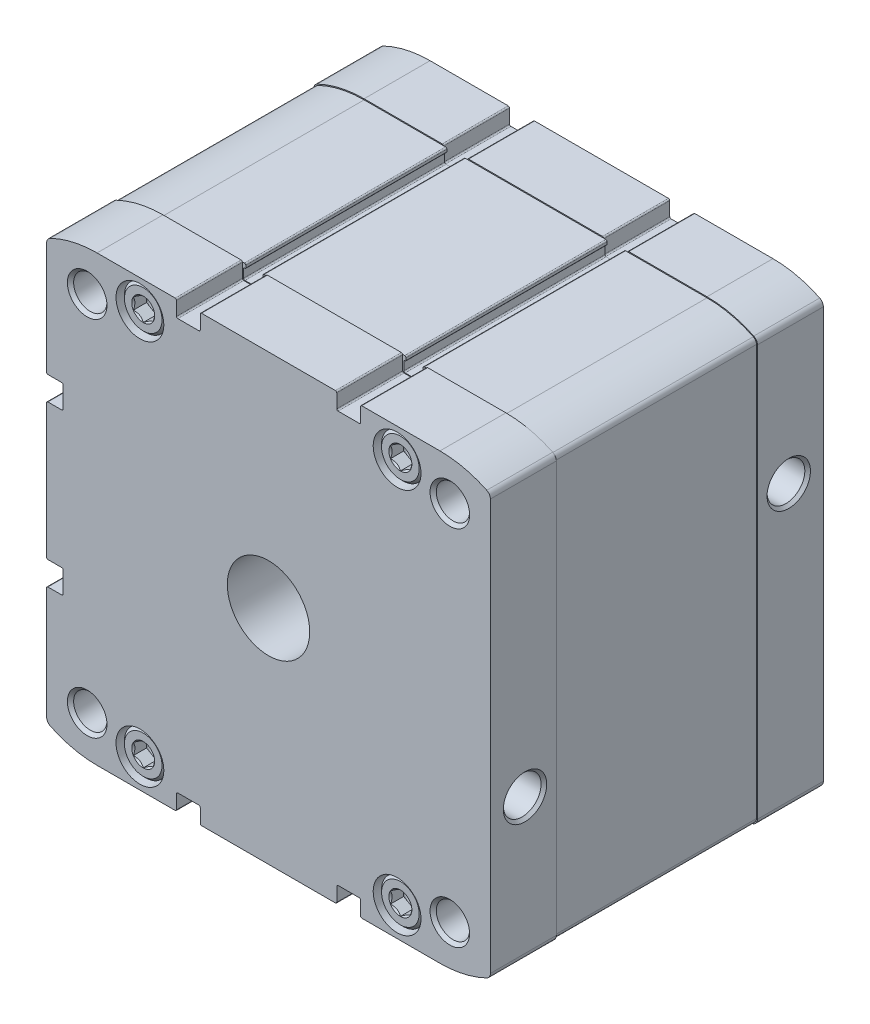
from build123d import *

# Parameters (mm, degrees)
BOSS_EXTRUDE1_DEPTH = 101
SKETCH2_W           = 134
SKETCH2_H           = 134
BOSS_EXTRUDE2_DEPTH = 61
SKETCH3_W           = 200
SKETCH3_H           = 200
CUT_EXTRUDE1_DEPTH  = 61
SKETCH7_W           = 2.6
SKETCH7_H           = 6
CUT_EXTRUDE2_DEPTH  = 4
CUT_EXTRUDE3_DEPTH  = 4
CUT_EXTRUDE4_DEPTH  = 4
CUT_EXTRUDE5_DEPTH  = 4
CUT_EXTRUDE6_DEPTH  = 4
CUT_EXTRUDE7_DEPTH  = 4
CUT_EXTRUDE8_DEPTH  = 4
CUT_EXTRUDE9_DEPTH  = 4
SKETCH29_W          = 61
SKETCH29_H          = 5.5
SKETCH31_W          = 61
SKETCH31_H          = 5.5
SKETCH33_W          = 61
SKETCH33_H          = 5.5
SKETCH35_W          = 61
SKETCH35_H          = 5.5


with BuildPart() as part:
    # Sketch1 → Boss-Extrude1 (new body)
    with BuildSketch(Plane.XY):
        with BuildLine():
            Line((-66.9, 27.9), (-62.7, 27.9))
            ThreePointArc((-62.7, 27.9), (-62.417157288, 27.782842712), (-62.3, 27.5))
            Line((-62.3, 27.5), (-62.3, 21.1))
            ThreePointArc((-62.3, 21.1), (-62.417157288, 20.817157288), (-62.7, 20.7))
            Line((-62.7, 20.7), (-66.9, 20.7))
            ThreePointArc((-66.9, 20.7), (-67.182842712, 20.582842712), (-67.3, 20.3))
            Line((-67.3, 20.3), (-67.3, -20.3))
            ThreePointArc((-67.3, -20.3), (-67.182842712, -20.582842712), (-66.9, -20.7))
            Line((-66.9, -20.7), (-62.7, -20.7))
            ThreePointArc((-62.7, -20.7), (-62.417157288, -20.817157288), (-62.3, -21.1))
            Line((-62.3, -21.1), (-62.3, -27.5))
            ThreePointArc((-62.3, -27.5), (-62.417157288, -27.782842712), (-62.7, -27.9))
            Line((-62.7, -27.9), (-66.9, -27.9))
            ThreePointArc((-66.9, -27.9), (-67.182842712, -28.017157288), (-67.3, -28.3))
            Line((-67.3, -28.3), (-67.3, -62.300902512))
            ThreePointArc((-67.3, -62.300902512), (-67.001263477, -63.338124248), (-66.196585713, -64.057544943))
            ThreePointArc((-66.196585713, -64.057544943), (-59.281080976, -66.479081854), (-52, -67.3))
            Line((-52, -67.3), (-28.3, -67.3))
            ThreePointArc((-28.3, -67.3), (-28.017157288, -67.182842712), (-27.9, -66.9))
            Line((-27.9, -66.9), (-27.9, -62.7))
            ThreePointArc((-27.9, -62.7), (-27.782842712, -62.417157288), (-27.5, -62.3))
            Line((-27.5, -62.3), (-21.1, -62.3))
            ThreePointArc((-21.1, -62.3), (-20.817157288, -62.417157288), (-20.7, -62.7))
            Line((-20.7, -62.7), (-20.7, -66.9))
            ThreePointArc((-20.7, -66.9), (-20.582842712, -67.182842712), (-20.3, -67.3))
            Line((-20.3, -67.3), (20.3, -67.3))
            ThreePointArc((20.3, -67.3), (20.582842712, -67.182842712), (20.7, -66.9))
            Line((20.7, -66.9), (20.7, -62.7))
            ThreePointArc((20.7, -62.7), (20.817157288, -62.417157288), (21.1, -62.3))
            Line((21.1, -62.3), (27.5, -62.3))
            ThreePointArc((27.5, -62.3), (27.782842712, -62.417157288), (27.9, -62.7))
            Line((27.9, -62.7), (27.9, -66.9))
            ThreePointArc((27.9, -66.9), (28.017157288, -67.182842712), (28.3, -67.3))
            Line((28.3, -67.3), (52, -67.3))
            ThreePointArc((52, -67.3), (59.281080788, -66.479081896), (66.196585366, -64.057545111))
            ThreePointArc((66.196585366, -64.057545111), (67.001263374, -63.338124412), (67.3, -62.300902512))
            Line((67.3, -62.300902512), (67.3, 62.300902512))
            ThreePointArc((67.3, 62.300902512), (67.001263433, 63.338124318), (66.196585566, 64.057545014))
            ThreePointArc((66.196585566, 64.057545014), (59.281080896, 66.479081872), (52, 67.3))
            Line((52, 67.3), (28.3, 67.3))
            ThreePointArc((28.3, 67.3), (28.017157288, 67.182842712), (27.9, 66.9))
            Line((27.9, 66.9), (27.9, 62.7))
            ThreePointArc((27.9, 62.7), (27.782842712, 62.417157288), (27.5, 62.3))
            Line((27.5, 62.3), (21.1, 62.3))
            ThreePointArc((21.1, 62.3), (20.817157288, 62.417157288), (20.7, 62.7))
            Line((20.7, 62.7), (20.7, 66.9))
            ThreePointArc((20.7, 66.9), (20.582842712, 67.182842712), (20.3, 67.3))
            Line((20.3, 67.3), (-20.3, 67.3))
            ThreePointArc((-20.3, 67.3), (-20.582842712, 67.182842712), (-20.7, 66.9))
            Line((-20.7, 66.9), (-20.7, 62.7))
            ThreePointArc((-20.7, 62.7), (-20.817157288, 62.417157288), (-21.1, 62.3))
            Line((-21.1, 62.3), (-27.5, 62.3))
            ThreePointArc((-27.5, 62.3), (-27.782842712, 62.417157288), (-27.9, 62.7))
            Line((-27.9, 62.7), (-27.9, 66.9))
            ThreePointArc((-27.9, 66.9), (-28.017157288, 67.182842712), (-28.3, 67.3))
            Line((-28.3, 67.3), (-52, 67.3))
            ThreePointArc((-52, 67.3), (-59.281080788, 66.479081896), (-66.196585366, 64.057545111))
            ThreePointArc((-66.196585366, 64.057545111), (-67.001263374, 63.338124412), (-67.3, 62.300902512))
            Line((-67.3, 62.300902512), (-67.3, 28.3))
            ThreePointArc((-67.3, 28.3), (-67.182842712, 28.017157288), (-66.9, 27.9))
        make_face()
    extrude(amount=-BOSS_EXTRUDE1_DEPTH)

    # Sketch2 → Boss-Extrude2 (add)
    with BuildSketch(Plane.XY.offset(-20)):
        Rectangle(SKETCH2_W, SKETCH2_H)
    extrude(amount=-BOSS_EXTRUDE2_DEPTH)

    # Sketch3 → Cut-Extrude1 (cut)
    with BuildSketch(Plane.XY.offset(-20)):
        Rectangle(SKETCH3_W, SKETCH3_H)
        with BuildLine():
            Line((-66.6, 26.9), (-65.9, 26.9))
            ThreePointArc((-65.9, 26.9), (-65.758578644, 26.958578644), (-65.7, 27.1))
            Line((-65.7, 27.1), (-65.7, 27.35))
            ThreePointArc((-65.7, 27.35), (-65.641421356, 27.491421356), (-65.5, 27.55))
            Line((-65.5, 27.55), (-62.9, 27.55))
            ThreePointArc((-62.9, 27.55), (-62.617157288, 27.432842712), (-62.5, 27.15))
            Line((-62.5, 27.15), (-62.5, 21.45))
            ThreePointArc((-62.5, 21.45), (-62.617157288, 21.167157288), (-62.9, 21.05))
            Line((-62.9, 21.05), (-65.5, 21.05))
            ThreePointArc((-65.5, 21.05), (-65.641421356, 21.108578644), (-65.7, 21.25))
            Line((-65.7, 21.25), (-65.7, 21.5))
            ThreePointArc((-65.7, 21.5), (-65.758578644, 21.641421356), (-65.9, 21.7))
            Line((-65.9, 21.7), (-66.6, 21.7))
            ThreePointArc((-66.6, 21.7), (-66.882842712, 21.582842712), (-67, 21.3))
            Line((-67, 21.3), (-67, -21.3))
            ThreePointArc((-67, -21.3), (-66.882842712, -21.582842712), (-66.6, -21.7))
            Line((-66.6, -21.7), (-65.9, -21.7))
            ThreePointArc((-65.9, -21.7), (-65.758578644, -21.641421356), (-65.7, -21.5))
            Line((-65.7, -21.5), (-65.7, -21.25))
            ThreePointArc((-65.7, -21.25), (-65.641421356, -21.108578644), (-65.5, -21.05))
            Line((-65.5, -21.05), (-62.9, -21.05))
            ThreePointArc((-62.9, -21.05), (-62.617157288, -21.167157288), (-62.5, -21.45))
            Line((-62.5, -21.45), (-62.5, -27.15))
            ThreePointArc((-62.5, -27.15), (-62.617157288, -27.432842712), (-62.9, -27.55))
            Line((-62.9, -27.55), (-65.5, -27.55))
            ThreePointArc((-65.5, -27.55), (-65.641421356, -27.491421356), (-65.7, -27.35))
            Line((-65.7, -27.35), (-65.7, -27.1))
            ThreePointArc((-65.7, -27.1), (-65.758578644, -26.958578644), (-65.9, -26.9))
            Line((-65.9, -26.9), (-66.6, -26.9))
            ThreePointArc((-66.6, -26.9), (-66.882842712, -27.017157288), (-67, -27.3))
            Line((-67, -27.3), (-67, -62.269477769))
            ThreePointArc((-67, -62.269477769), (-66.739100392, -63.174458466), (-66.036482279, -63.801663741))
            ThreePointArc((-66.036482279, -63.801663741), (-59.198128048, -66.190298394), (-52, -67))
            Line((-52, -67), (-27.3, -67))
            ThreePointArc((-27.3, -67), (-27.017157288, -66.882842712), (-26.9, -66.6))
            Line((-26.9, -66.6), (-26.9, -65.9))
            ThreePointArc((-26.9, -65.9), (-26.958578644, -65.758578644), (-27.1, -65.7))
            Line((-27.1, -65.7), (-27.35, -65.7))
            ThreePointArc((-27.35, -65.7), (-27.491421356, -65.641421356), (-27.55, -65.5))
            Line((-27.55, -65.5), (-27.55, -62.9))
            ThreePointArc((-27.55, -62.9), (-27.432842712, -62.617157288), (-27.15, -62.5))
            Line((-27.15, -62.5), (-21.45, -62.5))
            ThreePointArc((-21.45, -62.5), (-21.167157288, -62.617157288), (-21.05, -62.9))
            Line((-21.05, -62.9), (-21.05, -65.5))
            ThreePointArc((-21.05, -65.5), (-21.108578644, -65.641421356), (-21.25, -65.7))
            Line((-21.25, -65.7), (-21.5, -65.7))
            ThreePointArc((-21.5, -65.7), (-21.641421356, -65.758578644), (-21.7, -65.9))
            Line((-21.7, -65.9), (-21.7, -66.6))
            ThreePointArc((-21.7, -66.6), (-21.582842712, -66.882842712), (-21.3, -67))
            Line((-21.3, -67), (21.3, -67))
            ThreePointArc((21.3, -67), (21.582842712, -66.882842712), (21.7, -66.6))
            Line((21.7, -66.6), (21.7, -65.9))
            ThreePointArc((21.7, -65.9), (21.641421356, -65.758578644), (21.5, -65.7))
            Line((21.5, -65.7), (21.25, -65.7))
            ThreePointArc((21.25, -65.7), (21.108578644, -65.641421356), (21.05, -65.5))
            Line((21.05, -65.5), (21.05, -62.9))
            ThreePointArc((21.05, -62.9), (21.167157288, -62.617157288), (21.45, -62.5))
            Line((21.45, -62.5), (27.15, -62.5))
            ThreePointArc((27.15, -62.5), (27.432842712, -62.617157288), (27.55, -62.9))
            Line((27.55, -62.9), (27.55, -65.5))
            ThreePointArc((27.55, -65.5), (27.491421356, -65.641421356), (27.35, -65.7))
            Line((27.35, -65.7), (27.1, -65.7))
            ThreePointArc((27.1, -65.7), (26.958578644, -65.758578644), (26.9, -65.9))
            Line((26.9, -65.9), (26.9, -66.6))
            ThreePointArc((26.9, -66.6), (27.017157288, -66.882842712), (27.3, -67))
            Line((27.3, -67), (52, -67))
            ThreePointArc((52, -67), (59.198127943, -66.190298418), (66.036482085, -63.801663834))
            ThreePointArc((66.036482085, -63.801663834), (66.739100334, -63.174458558), (67, -62.269477769))
            Line((67, -62.269477769), (67, 62.269477769))
            ThreePointArc((67, 62.269477769), (66.739100392, 63.174458466), (66.036482279, 63.801663741))
            ThreePointArc((66.036482279, 63.801663741), (59.198128048, 66.190298394), (52, 67))
            Line((52, 67), (27.3, 67))
            ThreePointArc((27.3, 67), (27.017157288, 66.882842712), (26.9, 66.6))
            Line((26.9, 66.6), (26.9, 65.9))
            ThreePointArc((26.9, 65.9), (26.958578644, 65.758578644), (27.1, 65.7))
            Line((27.1, 65.7), (27.35, 65.7))
            ThreePointArc((27.35, 65.7), (27.491421356, 65.641421356), (27.55, 65.5))
            Line((27.55, 65.5), (27.55, 62.9))
            ThreePointArc((27.55, 62.9), (27.432842712, 62.617157288), (27.15, 62.5))
            Line((27.15, 62.5), (21.45, 62.5))
            ThreePointArc((21.45, 62.5), (21.167157288, 62.617157288), (21.05, 62.9))
            Line((21.05, 62.9), (21.05, 65.5))
            ThreePointArc((21.05, 65.5), (21.108578644, 65.641421356), (21.25, 65.7))
            Line((21.25, 65.7), (21.5, 65.7))
            ThreePointArc((21.5, 65.7), (21.641421356, 65.758578644), (21.7, 65.9))
            Line((21.7, 65.9), (21.7, 66.6))
            ThreePointArc((21.7, 66.6), (21.582842712, 66.882842712), (21.3, 67))
            Line((21.3, 67), (-21.3, 67))
            ThreePointArc((-21.3, 67), (-21.582842712, 66.882842712), (-21.7, 66.6))
            Line((-21.7, 66.6), (-21.7, 65.9))
            ThreePointArc((-21.7, 65.9), (-21.641421356, 65.758578644), (-21.5, 65.7))
            Line((-21.5, 65.7), (-21.25, 65.7))
            ThreePointArc((-21.25, 65.7), (-21.108578644, 65.641421356), (-21.05, 65.5))
            Line((-21.05, 65.5), (-21.05, 62.9))
            ThreePointArc((-21.05, 62.9), (-21.167157288, 62.617157288), (-21.45, 62.5))
            Line((-21.45, 62.5), (-27.15, 62.5))
            ThreePointArc((-27.15, 62.5), (-27.432842712, 62.617157288), (-27.55, 62.9))
            Line((-27.55, 62.9), (-27.55, 65.5))
            ThreePointArc((-27.55, 65.5), (-27.491421356, 65.641421356), (-27.35, 65.7))
            Line((-27.35, 65.7), (-27.1, 65.7))
            ThreePointArc((-27.1, 65.7), (-26.958578644, 65.758578644), (-26.9, 65.9))
            Line((-26.9, 65.9), (-26.9, 66.6))
            ThreePointArc((-26.9, 66.6), (-27.017157288, 66.882842712), (-27.3, 67))
            Line((-27.3, 67), (-52, 67))
            ThreePointArc((-52, 67), (-59.198127943, 66.190298418), (-66.036482085, 63.801663834))
            ThreePointArc((-66.036482085, 63.801663834), (-66.739100334, 63.174458558), (-67, 62.269477769))
            Line((-67, 62.269477769), (-67, 27.3))
            ThreePointArc((-67, 27.3), (-66.882842712, 27.017157288), (-66.6, 26.9))
        make_face(mode=Mode.SUBTRACT)
    extrude(amount=-CUT_EXTRUDE1_DEPTH, mode=Mode.SUBTRACT)

    # Sketch4 → Cut-Revolve1 (revolve, cut)
    with BuildSketch(Plane(origin=(0, -21.15, 0), x_dir=(1, 0, 0), z_dir=(0, 1, 0))):
        Polygon((39.5, 10.5), (39.5, 16.2225), (66.444, 16.2225), (67.3, 17.0785), (67.3, 10.5), align=None)
    revolve(axis=Axis((67.3, -21.15, -10.5), (-1, 0, 0)), mode=Mode.SUBTRACT)

    # Sketch5 → Cut-Revolve2 (revolve, cut)
    with BuildSketch(Plane(origin=(0, 21.15, 0), x_dir=(1, 0, 0), z_dir=(0, 1, 0))):
        Polygon((39.5, 90.5), (39.5, 96.2225), (66.444, 96.2225), (67.3, 97.0785), (67.3, 90.5), align=None)
    revolve(axis=Axis((67.3, 21.15, -90.5), (-1, 0, 0)), mode=Mode.SUBTRACT)

    # Sketch6 → Cut-Revolve3 (revolve, cut)
    with BuildSketch(Plane(origin=(0, 0, 0), x_dir=(0, 0, -1), z_dir=(1, 0, 0))):
        Polygon((-1, 0), (-1, 12.5), (28.75, 12.5), (28.75, 62.5), (80, 62.5), (80, 0), align=None)
    revolve(axis=Axis((0, 0, -80), (0, 0, 1)), mode=Mode.SUBTRACT)

    # Sketch7 → Cut-Revolve4 (revolve, cut)
    with BuildSketch(Plane(origin=(0, 0, 0), x_dir=(0, 0, -1), z_dir=(1, 0, 0))):
        with Locations((99.7, 3)):
            Rectangle(SKETCH7_W, SKETCH7_H)
    revolve(axis=Axis((0, 0, -101), (0, 0, 1)), mode=Mode.SUBTRACT)

    # Sketch8 → Cut-Revolve5 (revolve, cut)
    with BuildSketch(Plane(origin=(0, 58.5, 0), x_dir=(1, 0, 0), z_dir=(0, 1, 0))):
        Polygon((39, 5.803847577), (42, 5), (42, 1.48), (42.48, 1), (44.7, 1), (45.5, 1.8), (45.5, 9), (46.25, 9), (46.25, -1), (39, -1), align=None)
    revolve(axis=Axis((39, 58.5, 1), (0, 0, -1)), mode=Mode.SUBTRACT)

    # Sketch9 → Cut-Revolve6 (revolve, cut)
    with BuildSketch(Plane(origin=(0, 58.5, 0), x_dir=(1, 0, 0), z_dir=(0, 1, 0))):
        Polygon((-39, 5.803847577), (-36, 5), (-36, 1.48), (-35.52, 1), (-33.3, 1), (-32.5, 1.8), (-32.5, 9), (-31.75, 9), (-31.75, -1), (-39, -1), align=None)
    revolve(axis=Axis((-39, 58.5, 1), (0, 0, -1)), mode=Mode.SUBTRACT)

    # Sketch10 → Cut-Revolve7 (revolve, cut)
    with BuildSketch(Plane(origin=(0, -58.5, 0), x_dir=(1, 0, 0), z_dir=(0, 1, 0))):
        Polygon((39, 5.803847577), (42, 5), (42, 1.48), (42.48, 1), (44.7, 1), (45.5, 1.8), (45.5, 9), (46.25, 9), (46.25, -1), (39, -1), align=None)
    revolve(axis=Axis((39, -58.5, 1), (0, 0, -1)), mode=Mode.SUBTRACT)

    # Sketch11 → Cut-Revolve8 (revolve, cut)
    with BuildSketch(Plane(origin=(0, -58.5, 0), x_dir=(1, 0, 0), z_dir=(0, 1, 0))):
        Polygon((-39, 5.803847577), (-36, 5), (-36, 1.48), (-35.52, 1), (-33.3, 1), (-32.5, 1.8), (-32.5, 9), (-31.75, 9), (-31.75, -1), (-39, -1), align=None)
    revolve(axis=Axis((-39, -58.5, 1), (0, 0, -1)), mode=Mode.SUBTRACT)

    # Sketch12 → Cut-Revolve9 (revolve, cut)
    with BuildSketch(Plane(origin=(0, 58.5, 0), x_dir=(1, 0, 0), z_dir=(0, 1, 0))):
        Polygon((39, 102), (46.25, 102), (46.25, 92), (45.5, 92), (45.5, 99.2), (44.7, 100), (42.48, 100), (42, 99.52), (42, 96), (39, 95.196152423), align=None)
    revolve(axis=Axis((39, 58.5, -95.196152423), (0, 0, -1)), mode=Mode.SUBTRACT)

    # Sketch13 → Cut-Revolve10 (revolve, cut)
    with BuildSketch(Plane(origin=(0, 58.5, 0), x_dir=(1, 0, 0), z_dir=(0, 1, 0))):
        Polygon((-39, 102), (-31.75, 102), (-31.75, 92), (-32.5, 92), (-32.5, 99.2), (-33.3, 100), (-35.52, 100), (-36, 99.52), (-36, 96), (-39, 95.196152423), align=None)
    revolve(axis=Axis((-39, 58.5, -95.196152423), (0, 0, -1)), mode=Mode.SUBTRACT)

    # Sketch14 → Cut-Revolve11 (revolve, cut)
    with BuildSketch(Plane(origin=(0, -58.5, 0), x_dir=(1, 0, 0), z_dir=(0, 1, 0))):
        Polygon((-39, 102), (-31.75, 102), (-31.75, 92), (-32.5, 92), (-32.5, 99.2), (-33.3, 100), (-35.52, 100), (-36, 99.52), (-36, 96), (-39, 95.196152423), align=None)
    revolve(axis=Axis((-39, -58.5, -95.196152423), (0, 0, -1)), mode=Mode.SUBTRACT)

    # Sketch15 → Cut-Revolve12 (revolve, cut)
    with BuildSketch(Plane(origin=(0, -58.5, 0), x_dir=(1, 0, 0), z_dir=(0, 1, 0))):
        Polygon((39, 102), (46.25, 102), (46.25, 92), (45.5, 92), (45.5, 99.2), (44.7, 100), (42.48, 100), (42, 99.52), (42, 96), (39, 95.196152423), align=None)
    revolve(axis=Axis((39, -58.5, -95.196152423), (0, 0, -1)), mode=Mode.SUBTRACT)

    # Sketch16 → Cut-Extrude2 (cut)
    with BuildSketch(Plane.XY.offset(-1)):
        Polygon((36, 56.767949192), (39, 55.035898385), (42, 56.767949192), (42, 60.232050808), (39, 61.964101615), (36, 60.232050808), align=None)
    extrude(amount=-CUT_EXTRUDE2_DEPTH, mode=Mode.SUBTRACT)

    # Sketch17 → Cut-Extrude3 (cut)
    with BuildSketch(Plane.XY.offset(-1)):
        Polygon((-42, 56.767949192), (-39, 55.035898385), (-36, 56.767949192), (-36, 60.232050808), (-39, 61.964101615), (-42, 60.232050808), align=None)
    extrude(amount=-CUT_EXTRUDE3_DEPTH, mode=Mode.SUBTRACT)

    # Sketch18 → Cut-Extrude4 (cut)
    with BuildSketch(Plane.XY.offset(-1)):
        Polygon((-42, -60.232050808), (-39, -61.964101615), (-36, -60.232050808), (-36, -56.767949192), (-39, -55.035898385), (-42, -56.767949192), align=None)
    extrude(amount=-CUT_EXTRUDE4_DEPTH, mode=Mode.SUBTRACT)

    # Sketch19 → Cut-Extrude5 (cut)
    with BuildSketch(Plane.XY.offset(-1)):
        Polygon((36, -60.232050808), (39, -61.964101615), (42, -60.232050808), (42, -56.767949192), (39, -55.035898385), (36, -56.767949192), align=None)
    extrude(amount=-CUT_EXTRUDE5_DEPTH, mode=Mode.SUBTRACT)

    # Sketch20 → Cut-Extrude6 (cut)
    with BuildSketch(Plane.XY.offset(-100)):
        Polygon((36, 56.767949192), (39, 55.035898385), (42, 56.767949192), (42, 60.232050808), (39, 61.964101615), (36, 60.232050808), align=None)
    extrude(amount=CUT_EXTRUDE6_DEPTH, mode=Mode.SUBTRACT)

    # Sketch21 → Cut-Extrude7 (cut)
    with BuildSketch(Plane.XY.offset(-100)):
        Polygon((-42, 56.767949192), (-39, 55.035898385), (-36, 56.767949192), (-36, 60.232050808), (-39, 61.964101615), (-42, 60.232050808), align=None)
    extrude(amount=CUT_EXTRUDE7_DEPTH, mode=Mode.SUBTRACT)

    # Sketch22 → Cut-Extrude8 (cut)
    with BuildSketch(Plane.XY.offset(-100)):
        Polygon((-42, -60.232050808), (-39, -61.964101615), (-36, -60.232050808), (-36, -56.767949192), (-39, -55.035898385), (-42, -56.767949192), align=None)
    extrude(amount=CUT_EXTRUDE8_DEPTH, mode=Mode.SUBTRACT)

    # Sketch23 → Cut-Extrude9 (cut)
    with BuildSketch(Plane.XY.offset(-100)):
        Polygon((36, -60.232050808), (39, -61.964101615), (42, -60.232050808), (42, -56.767949192), (39, -55.035898385), (36, -56.767949192), align=None)
    extrude(amount=CUT_EXTRUDE9_DEPTH, mode=Mode.SUBTRACT)

    # Sketch24 → Cut-Revolve13 (revolve, cut)
    with BuildSketch(Plane(origin=(55, 0, 0), x_dir=(0, 0, -1), z_dir=(1, 0, 0))):
        Polygon((0, 55), (0, 61), (0.947, 60.053), (20, 60.053), (20, 55), align=None)
    revolve(axis=Axis((55, 55, -20), (0, 0, 1)), mode=Mode.SUBTRACT)

    # Sketch25 → Cut-Revolve14 (revolve, cut)
    with BuildSketch(Plane(origin=(-55, 0, 0), x_dir=(0, 0, -1), z_dir=(1, 0, 0))):
        Polygon((0, 55), (0, 61), (0.947, 60.053), (20, 60.053), (20, 55), align=None)
    revolve(axis=Axis((-55, 55, -20), (0, 0, 1)), mode=Mode.SUBTRACT)

    # Sketch26 → Cut-Revolve15 (revolve, cut)
    with BuildSketch(Plane(origin=(55, 0, 0), x_dir=(0, 0, -1), z_dir=(1, 0, 0))):
        Polygon((0, -55), (0, -49), (0.947, -49.947), (20, -49.947), (20, -55), align=None)
    revolve(axis=Axis((55, -55, -20), (0, 0, 1)), mode=Mode.SUBTRACT)

    # Sketch27 → Cut-Revolve16 (revolve, cut)
    with BuildSketch(Plane(origin=(-55, 0, 0), x_dir=(0, 0, -1), z_dir=(1, 0, 0))):
        Polygon((0, -55), (0, -49), (0.947, -49.947), (20, -49.947), (20, -55), align=None)
    revolve(axis=Axis((-55, -55, -20), (0, 0, 1)), mode=Mode.SUBTRACT)

    # Sketch28 → Cut-Revolve17 (revolve, cut)
    with BuildSketch(Plane(origin=(55, 0, 0), x_dir=(0, 0, -1), z_dir=(1, 0, 0))):
        Polygon((81, 55), (81, 60.053), (100.053, 60.053), (101, 61), (101, 55), align=None)
    revolve(axis=Axis((55, 55, -101), (0, 0, 1)), mode=Mode.SUBTRACT)

    # Sketch29 → Cut-Revolve18 (revolve, cut)
    with BuildSketch(Plane(origin=(55, 0, 0), x_dir=(0, 0, -1), z_dir=(1, 0, 0))):
        with Locations((50.5, 57.75)):
            Rectangle(SKETCH29_W, SKETCH29_H)
    revolve(axis=Axis((55, 55, -81), (0, 0, 1)), mode=Mode.SUBTRACT)

    # Sketch30 → Cut-Revolve19 (revolve, cut)
    with BuildSketch(Plane(origin=(-55, 0, 0), x_dir=(0, 0, -1), z_dir=(1, 0, 0))):
        Polygon((81, 55), (81, 60.053), (100.053, 60.053), (101, 61), (101, 55), align=None)
    revolve(axis=Axis((-55, 55, -101), (0, 0, 1)), mode=Mode.SUBTRACT)

    # Sketch31 → Cut-Revolve20 (revolve, cut)
    with BuildSketch(Plane(origin=(-55, 0, 0), x_dir=(0, 0, -1), z_dir=(1, 0, 0))):
        with Locations((50.5, 57.75)):
            Rectangle(SKETCH31_W, SKETCH31_H)
    revolve(axis=Axis((-55, 55, -81), (0, 0, 1)), mode=Mode.SUBTRACT)

    # Sketch32 → Cut-Revolve21 (revolve, cut)
    with BuildSketch(Plane(origin=(55, 0, 0), x_dir=(0, 0, -1), z_dir=(1, 0, 0))):
        Polygon((81, -55), (81, -49.947), (100.053, -49.947), (101, -49), (101, -55), align=None)
    revolve(axis=Axis((55, -55, -101), (0, 0, 1)), mode=Mode.SUBTRACT)

    # Sketch33 → Cut-Revolve22 (revolve, cut)
    with BuildSketch(Plane(origin=(55, 0, 0), x_dir=(0, 0, -1), z_dir=(1, 0, 0))):
        with Locations((50.5, -52.25)):
            Rectangle(SKETCH33_W, SKETCH33_H)
    revolve(axis=Axis((55, -55, -81), (0, 0, 1)), mode=Mode.SUBTRACT)

    # Sketch34 → Cut-Revolve23 (revolve, cut)
    with BuildSketch(Plane(origin=(-55, 0, 0), x_dir=(0, 0, -1), z_dir=(1, 0, 0))):
        Polygon((81, -55), (81, -49.947), (100.053, -49.947), (101, -49), (101, -55), align=None)
    revolve(axis=Axis((-55, -55, -101), (0, 0, 1)), mode=Mode.SUBTRACT)

    # Sketch35 → Cut-Revolve24 (revolve, cut)
    with BuildSketch(Plane(origin=(-55, 0, 0), x_dir=(0, 0, -1), z_dir=(1, 0, 0))):
        with Locations((50.5, -52.25)):
            Rectangle(SKETCH35_W, SKETCH35_H)
    revolve(axis=Axis((-55, -55, -81), (0, 0, 1)), mode=Mode.SUBTRACT)


solid = part.part
